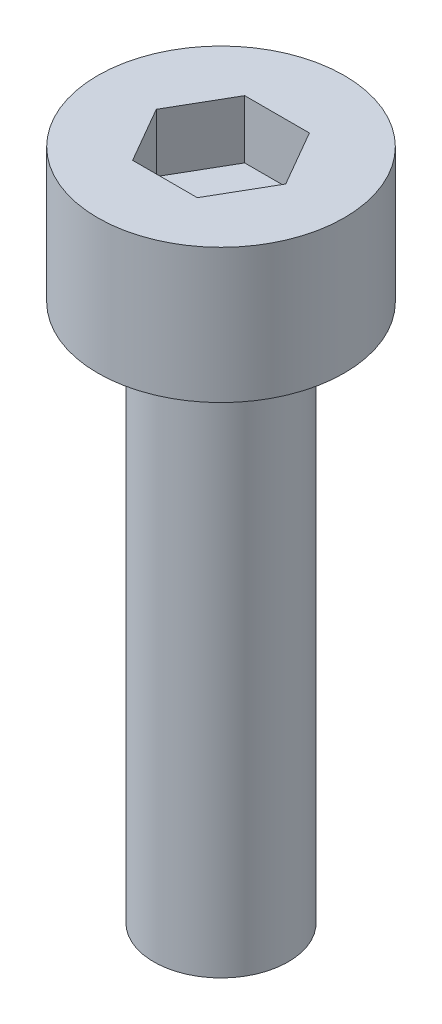
from build123d import *

# Parameters (mm, degrees)
SKETCH_1_R            = 2.75
EXTRUDE_248_DEPTH     = 3
CUT_EXTRUDE_378_DEPTH = 1.3
SKETCH_3_R            = 1.5
EXTRUDE_479_DEPTH     = 12


with BuildPart() as part:
    # 草图1 → Extrude 248 (new body)
    with BuildSketch(Plane(origin=(0, 0, 0), x_dir=(1, 0, 0), z_dir=(0, 1, 0))):
        Circle(SKETCH_1_R)
    extrude(amount=EXTRUDE_248_DEPTH)

    # 草图2 → Cut-Extrude 378 (cut)
    with BuildSketch(Plane(origin=(0, 3, 0), x_dir=(1, 0, 0), z_dir=(0, 1, 0))):
        Polygon((1.443375673, 0), (0.721687836, 1.25), (-0.721687836, 1.25), (-1.443375673, 0), (-0.721687836, -1.25), (0.721687836, -1.25), align=None)
    extrude(amount=-CUT_EXTRUDE_378_DEPTH, mode=Mode.SUBTRACT)

    # 草图3 → Extrude 479 (add)
    with BuildSketch(Plane.XZ):
        Circle(SKETCH_3_R)
    extrude(amount=EXTRUDE_479_DEPTH)


solid = part.part
